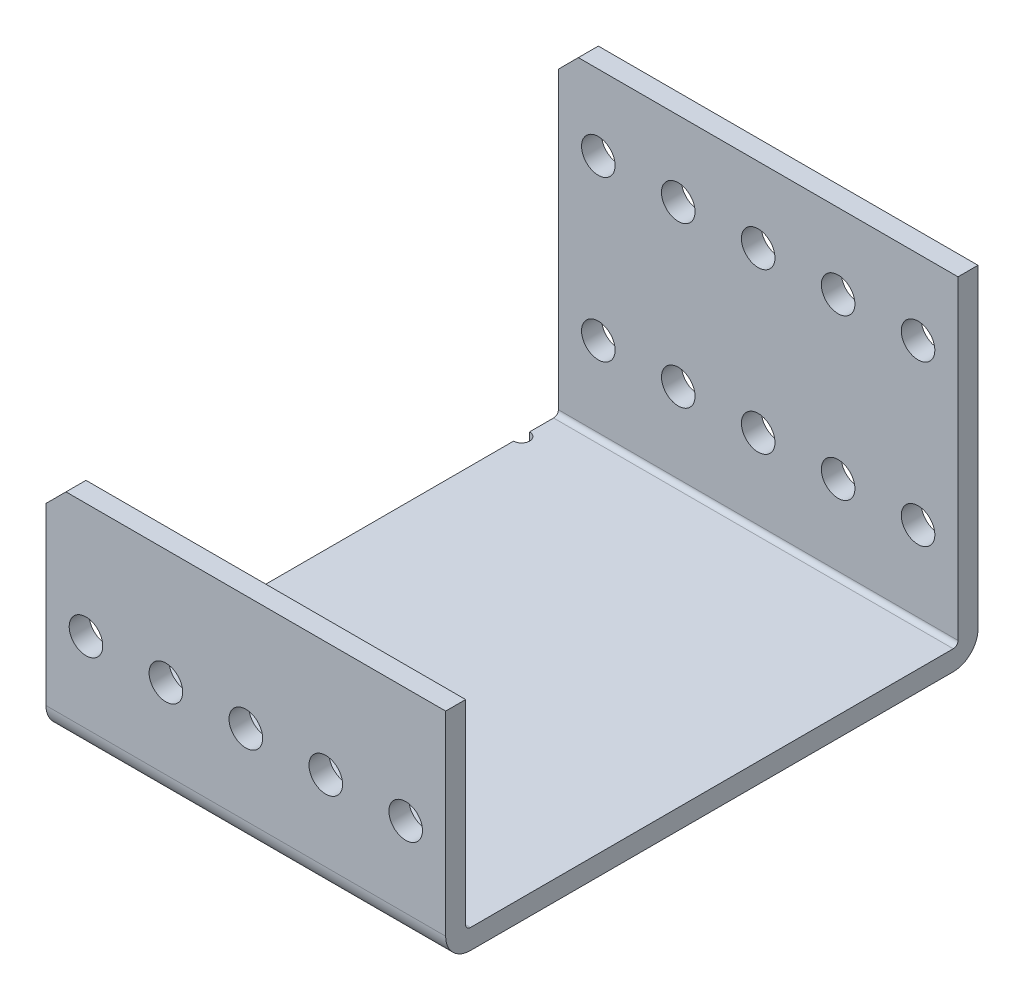
from build123d import *

# Parameters (mm, degrees)
SKETCH1_W            = 698.5
SKETCH1_H            = 84.582
BOSS_EXTRUDE1_DEPTH  = 34.925
SKETCH2_W            = 81.407
SKETCH2_H            = 31.75
CUT_EXTRUDE1_DEPTH   = 699.5
SKETCH3_W            = 698.5
SKETCH3_H            = 3.175
BOSS_EXTRUDE2_DEPTH  = 50.8
M2_CLEARANCE_HOLE1_D = 2.54
M5_CLEARANCE_HOLE1_D = 5.334
CHAMFER1_SIZE        = 3.175
FILLET1_R            = 0.762
FILLET2_R            = 3.937
SKETCH8_W            = 725.924928317
SKETCH8_H            = 218.216354959
CUT_EXTRUDE2_DEPTH   = 85.582


with BuildPart() as part:
    # Sketch1 → Boss-Extrude1 (new body)
    with BuildSketch(Plane(origin=(0, 57.816398039, 0), x_dir=(1, 0, 0), z_dir=(0, 1, 0))):
        with Locations((253.148031467, -103.269491579)):
            Rectangle(SKETCH1_W, SKETCH1_H)
    extrude(amount=-BOSS_EXTRUDE1_DEPTH)

    # Sketch2 → Cut-Extrude1 (cut, through all)
    with BuildSketch(Plane(origin=(602.398031467, 0, 0), x_dir=(0, 0, -1), z_dir=(1, 0, 0))):
        with Locations((-101.681991579, 41.941398039)):
            Rectangle(SKETCH2_W, SKETCH2_H)
    extrude(amount=-CUT_EXTRUDE1_DEPTH, mode=Mode.SUBTRACT)

    # Sketch3 → Boss-Extrude2 (add)
    with BuildSketch(Plane(origin=(0, 26.066398039, 0), x_dir=(-1, 0, 0), z_dir=(0, 1, 0))):
        with Locations((-253.148031467, 62.565991579)):
            Rectangle(SKETCH3_W, SKETCH3_H)
    extrude(amount=BOSS_EXTRUDE2_DEPTH)

    # M2 Clearance Hole1 (through all)
    with Locations(Plane(origin=(0, 26.066398039, 0), x_dir=(1, 0, 0), z_dir=(0, 1, 0))):
        with Locations((-96.101968533, -136.543491579), (-96.101968533, -69.995491579)):
            Hole(M2_CLEARANCE_HOLE1_D / 2)

    # M5 Clearance Hole1 (through all)
    with Locations(Plane(origin=(0, 0, 60.978491579), x_dir=(-1, 0, 0), z_dir=(0, 0, -1))):
        with Locations((-469.048031467, 64.928398039), (-481.748031467, 64.928398039), (-469.048031467, 39.528398039), (-481.748031467, 39.528398039), (-456.348031467, 39.528398039), (-443.648031467, 39.528398039), (-430.948031467, 39.528398039), (-418.248031467, 39.528398039), (-405.548031467, 39.528398039), (-392.848031467, 39.528398039), (-380.148031467, 39.528398039), (-367.448031467, 39.528398039), (-354.748031467, 39.528398039), (-342.048031467, 39.528398039), (-329.348031467, 39.528398039), (-316.648031467, 39.528398039), (-303.948031467, 39.528398039), (-291.248031467, 39.528398039), (-278.548031467, 39.528398039), (-265.848031467, 39.528398039), (-253.148031467, 39.528398039), (-240.448031467, 39.528398039), (-227.748031467, 39.528398039), (-215.048031467, 39.528398039), (-202.348031467, 39.528398039), (-189.648031467, 39.528398039), (-176.948031467, 39.528398039), (-164.248031467, 39.528398039), (-151.548031467, 39.528398039), (-138.848031467, 39.528398039), (-126.148031467, 39.528398039), (-113.448031467, 39.528398039), (-100.748031467, 39.528398039), (-88.048031467, 39.528398039), (-75.348031467, 39.528398039), (-62.648031467, 39.528398039), (-49.948031467, 39.528398039), (-37.248031467, 39.528398039), (-24.548031467, 39.528398039), (-11.848031467, 39.528398039), (0.851968533, 39.528398039), (13.551968533, 39.528398039), (26.251968533, 39.528398039), (38.951968533, 39.528398039), (51.651968533, 39.528398039), (64.351968533, 39.528398039), (77.051968533, 39.528398039), (89.751968533, 39.528398039), (-456.348031467, 64.928398039), (-443.648031467, 64.928398039), (-430.948031467, 64.928398039), (-418.248031467, 64.928398039), (-405.548031467, 64.928398039), (-392.848031467, 64.928398039), (-380.148031467, 64.928398039), (-367.448031467, 64.928398039), (-354.748031467, 64.928398039), (-342.048031467, 64.928398039), (-329.348031467, 64.928398039), (-316.648031467, 64.928398039), (-303.948031467, 64.928398039), (-291.248031467, 64.928398039), (-278.548031467, 64.928398039), (-265.848031467, 64.928398039), (-253.148031467, 64.928398039), (-240.448031467, 64.928398039), (-227.748031467, 64.928398039), (-215.048031467, 64.928398039), (-202.348031467, 64.928398039), (-189.648031467, 64.928398039), (-176.948031467, 64.928398039), (-164.248031467, 64.928398039), (-151.548031467, 64.928398039), (-138.848031467, 64.928398039), (-126.148031467, 64.928398039), (-113.448031467, 64.928398039), (-100.748031467, 64.928398039), (-88.048031467, 64.928398039), (-75.348031467, 64.928398039), (-62.648031467, 64.928398039), (-49.948031467, 64.928398039), (-37.248031467, 64.928398039), (-24.548031467, 64.928398039), (-11.848031467, 64.928398039), (0.851968533, 64.928398039), (13.551968533, 64.928398039), (26.251968533, 64.928398039), (38.951968533, 64.928398039), (51.651968533, 64.928398039), (64.351968533, 64.928398039), (77.051968533, 64.928398039), (89.751968533, 64.928398039), (-494.448031467, 64.928398039), (-494.448031467, 39.528398039), (-507.148031467, 64.928398039), (-507.148031467, 39.528398039), (-519.848031467, 64.928398039), (-519.848031467, 39.528398039), (-532.548031467, 64.928398039), (-532.548031467, 39.528398039), (-545.248031467, 64.928398039), (-545.248031467, 39.528398039), (-557.948031467, 64.928398039), (-557.948031467, 39.528398039), (-570.648031467, 64.928398039), (-570.648031467, 39.528398039), (-583.348031467, 64.928398039), (-583.348031467, 39.528398039), (-596.048031467, 64.928398039), (-596.048031467, 39.528398039)):
            Hole(M5_CLEARANCE_HOLE1_D / 2)

    # Chamfer1
    chamfer1_edges = [part.edges().sort_by_distance(p)[0] for p in [
        (-96.101968533, 57.816398039, 143.972991579),
        (-96.101968533, 76.866398039, 62.565991579),
        (602.398031467, 76.866398039, 62.565991579),
        (602.398031467, 57.816398039, 143.972991579),
    ]]
    chamfer(chamfer1_edges, length=CHAMFER1_SIZE)

    # Fillet1
    fillet1_edges = [part.edges().sort_by_distance(p)[0] for p in [
        (253.148031467, 26.066398039, 142.385491579),
        (253.148031467, 26.066398039, 64.153491579),
    ]]
    fillet(fillet1_edges, radius=FILLET1_R)

    # Fillet2
    fillet2_edges = [part.edges().sort_by_distance(p)[0] for p in [
        (253.148031467, 22.891398039, 60.978491579),
        (253.148031467, 22.891398039, 145.560491579),
    ]]
    fillet(fillet2_edges, radius=FILLET2_R)

    # Sketch8 → Cut-Extrude2 (cut, through all)
    with BuildSketch(Plane(origin=(0, 0, 60.978491579), x_dir=(-1, 0, 0), z_dir=(0, 0, -1))):
        with Locations((-330.360495626, 61.250645378)):
            Rectangle(SKETCH8_W, SKETCH8_H)
    extrude(amount=-CUT_EXTRUDE2_DEPTH, mode=Mode.SUBTRACT)


solid = part.part
